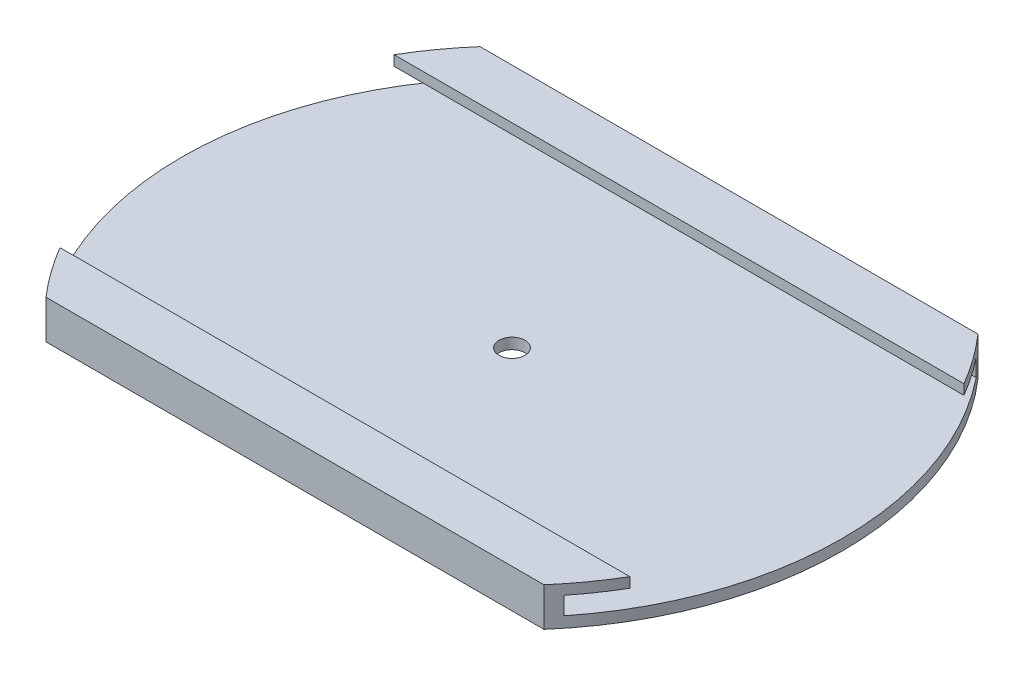
from build123d import *

# Parameters (mm, degrees)
BOSS_EXTRUDE1_DEPTH     = 8.9
SKETCH4_W               = 94.9
SKETCH4_H               = 4.080124435
CUT_EXTRUDE1_DEPTH      = 77.015080741
CUT_EXTRUDE1_DEPTH_BACK = 77.015080741
SKETCH7_W               = 76.9
SKETCH7_H               = 2.319875565
CUT_EXTRUDE2_DEPTH      = 77.015080741
CUT_EXTRUDE2_DEPTH_BACK = 77.015080741
SKETCH8_R               = 3
CUT_EXTRUDE3_DEPTH      = 7.4
CUT_EXTRUDE3_DEPTH_BACK = 3.5


with BuildPart() as part:
    # Sketch3 → Boss-Extrude1 (new body)
    with BuildSketch(Plane(origin=(0, 0, 0), x_dir=(1, 0, 0), z_dir=(0, 1, 0))):
        with BuildLine():
            Line((-57.3, 49.95), (57.3, 49.95))
            ThreePointArc((57.3, 49.95), (76.015080741, 0), (57.3, -49.95))
            Line((57.3, -49.95), (-57.3, -49.95))
            ThreePointArc((-57.3, -49.95), (-76.015080741, 0), (-57.3, 49.95))
        make_face()
    extrude(amount=BOSS_EXTRUDE1_DEPTH)

    # Sketch4 → Cut-Extrude1 (cut, two sides)
    with BuildSketch(Plane(origin=(0, 0, 0), x_dir=(0, 0, -1), z_dir=(1, 0, 0))) as cut_extrude1_sk:
        with Locations((0, 4.540062218)):
            Rectangle(SKETCH4_W, SKETCH4_H)
    extrude(amount=CUT_EXTRUDE1_DEPTH, mode=Mode.SUBTRACT)
    extrude(cut_extrude1_sk.sketch, amount=-CUT_EXTRUDE1_DEPTH_BACK, mode=Mode.SUBTRACT)

    # Sketch7 → Cut-Extrude2 (cut, two sides)
    with BuildSketch(Plane(origin=(0, 0, 0), x_dir=(0, 0, -1), z_dir=(1, 0, 0))) as cut_extrude2_sk:
        with Locations((0, 7.740062218)):
            Rectangle(SKETCH7_W, SKETCH7_H)
    extrude(amount=CUT_EXTRUDE2_DEPTH, mode=Mode.SUBTRACT)
    extrude(cut_extrude2_sk.sketch, amount=-CUT_EXTRUDE2_DEPTH_BACK, mode=Mode.SUBTRACT)

    # Sketch8 → Cut-Extrude3 (cut, two sides)
    with BuildSketch(Plane(origin=(0, 2.5, 0), x_dir=(1, 0, 0), z_dir=(0, 1, 0))) as cut_extrude3_sk:
        Circle(SKETCH8_R)
    extrude(amount=CUT_EXTRUDE3_DEPTH, mode=Mode.SUBTRACT)
    extrude(cut_extrude3_sk.sketch, amount=-CUT_EXTRUDE3_DEPTH_BACK, mode=Mode.SUBTRACT)


solid = part.part
